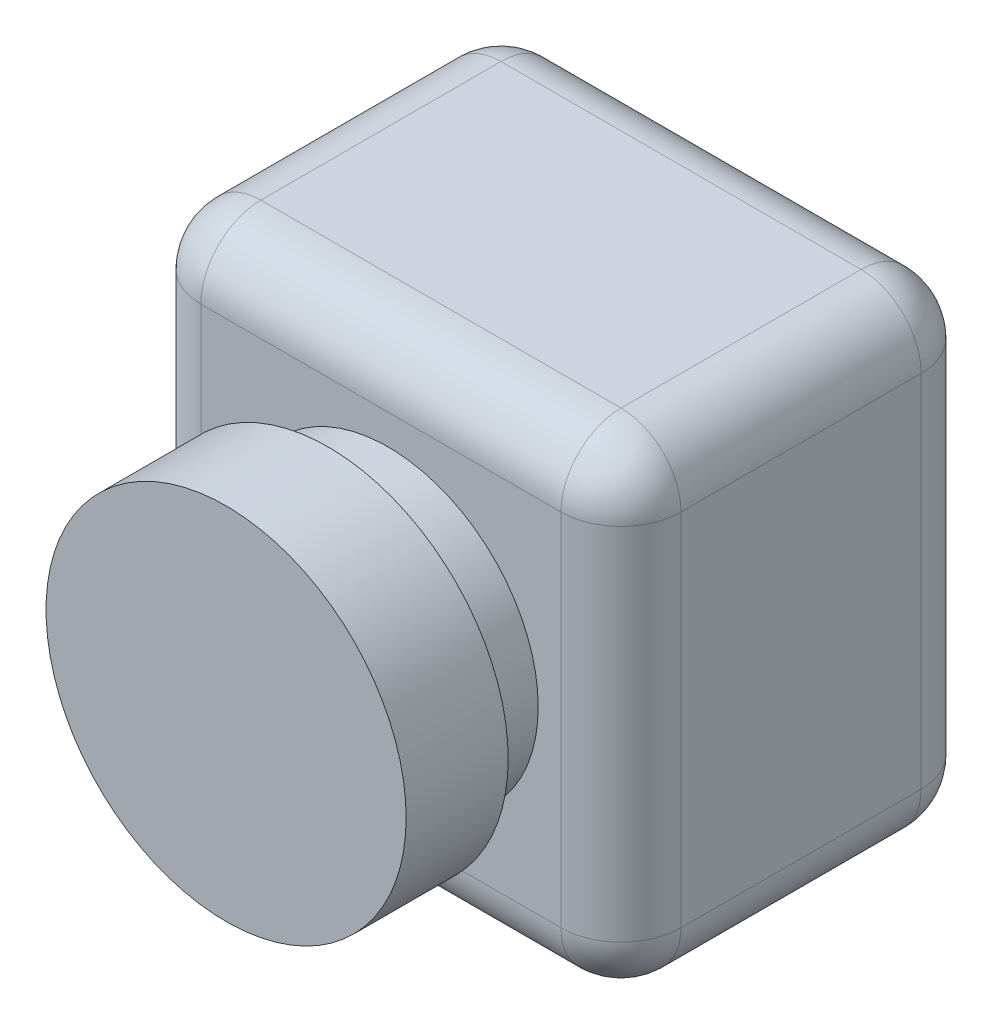
from build123d import *

# Parameters (mm, degrees)
SKETCH_1_W      = 80
SKETCH_1_H      = 80
EXTRUDE_1_DEPTH = 60
FILLET_1_R      = 10
SKETCH_2_R      = 25
EXTRUDE_2_DEPTH = 10
SKETCH_3_R      = 30
EXTRUDE_3_DEPTH = 17


with BuildPart() as part:
    # 스케치1 → 보스-돌출1 (new body)
    with BuildSketch(Plane.XY):
        with Locations((40, -40)):
            Rectangle(SKETCH_1_W, SKETCH_1_H)
    extrude(amount=EXTRUDE_1_DEPTH)

    # 필렛1
    fillet_1_edges = [part.edges().sort_by_distance(p)[0] for p in [
        (80, -40, 60),
        (40, 0, 60),
        (0, -40, 60),
        (40, 0, 0),
        (80, -40, 0),
        (40, -80, 0),
        (0, -40, 0),
        (40, -80, 60),
        (0, 0, 30),
        (80, 0, 30),
        (80, -80, 30),
        (0, -80, 30),
    ]]
    fillet(fillet_1_edges, radius=FILLET_1_R)

    # 스케치2 → 보스-돌출2 (add)
    with BuildSketch(Plane.XY.offset(60)):
        with Locations((41.207439788, -40)):
            Circle(SKETCH_2_R)
    extrude(amount=EXTRUDE_2_DEPTH)

    # 스케치3 → 보스-돌출3 (add)
    with BuildSketch(Plane.XY.offset(70)):
        with Locations((41.207439788, -40)):
            Circle(SKETCH_3_R)
    extrude(amount=EXTRUDE_3_DEPTH)


solid = part.part
